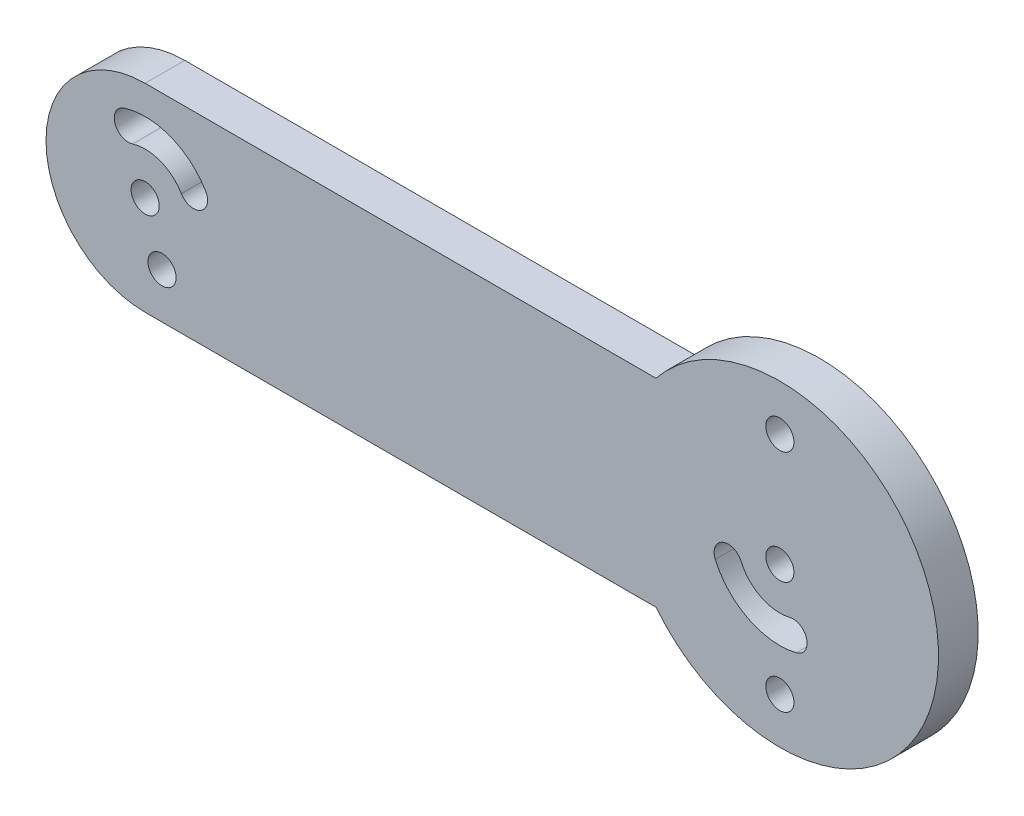
from build123d import *

# Parameters (mm, degrees)
SKETCH1_R           = 0.8875
BOSS_EXTRUDE1_DEPTH = 2.5


with BuildPart() as part:
    # Sketch1 → Boss-Extrude1 (new body)
    with BuildSketch(Plane.XY):
        with BuildLine():
            Line((-40, 6.25), (-7.806247498, 6.25))
            ThreePointArc((-7.806247498, 6.25), (10, 0), (-7.806247498, -6.25))
            Line((-7.806247498, -6.25), (-40, -6.25))
            ThreePointArc((-40, -6.25), (-46.25, 0), (-40, 6.25))
        make_face()
        Circle(SKETCH1_R, mode=Mode.SUBTRACT)
        with Locations((-40, 0)):
            Circle(SKETCH1_R, mode=Mode.SUBTRACT)
        with Locations((0, 7.1)):
            Circle(SKETCH1_R, mode=Mode.SUBTRACT)
        with Locations((0, -7.1)):
            Circle(SKETCH1_R, mode=Mode.SUBTRACT)
        with Locations((-38.938319925, -3.387526445)):
            Circle(SKETCH1_R, mode=Mode.SUBTRACT)
        with BuildLine():
            ThreePointArc((-36.192394339, 2.278935142), (-38.420697766, 4.146951977), (-41.327100094, 4.234408057))
            ThreePointArc((-41.327100094, 4.234408057), (-41.908561687, 3.122106427), (-40.796260056, 2.540644834))
            ThreePointArc((-40.796260056, 2.540644834), (-39.05241866, 2.488171186), (-37.715436604, 1.367361085))
            ThreePointArc((-37.715436604, 1.367361085), (-36.498128443, 1.061626982), (-36.192394339, 2.278935142))
        make_face(mode=Mode.SUBTRACT)
        with BuildLine():
            ThreePointArc((-4.06945408, -1.769448993), (-1.980002796, -3.97127123), (1.035913802, -4.314891522))
            ThreePointArc((1.035913802, -4.314891522), (1.691709346, -3.244730457), (0.621548281, -2.588934913))
            ThreePointArc((0.621548281, -2.588934913), (-1.188001677, -2.382762738), (-2.441672448, -1.061669396))
            ThreePointArc((-2.441672448, -1.061669396), (-3.609453063, -0.601668379), (-4.06945408, -1.769448993))
        make_face(mode=Mode.SUBTRACT)
    extrude(amount=BOSS_EXTRUDE1_DEPTH)


solid = part.part
